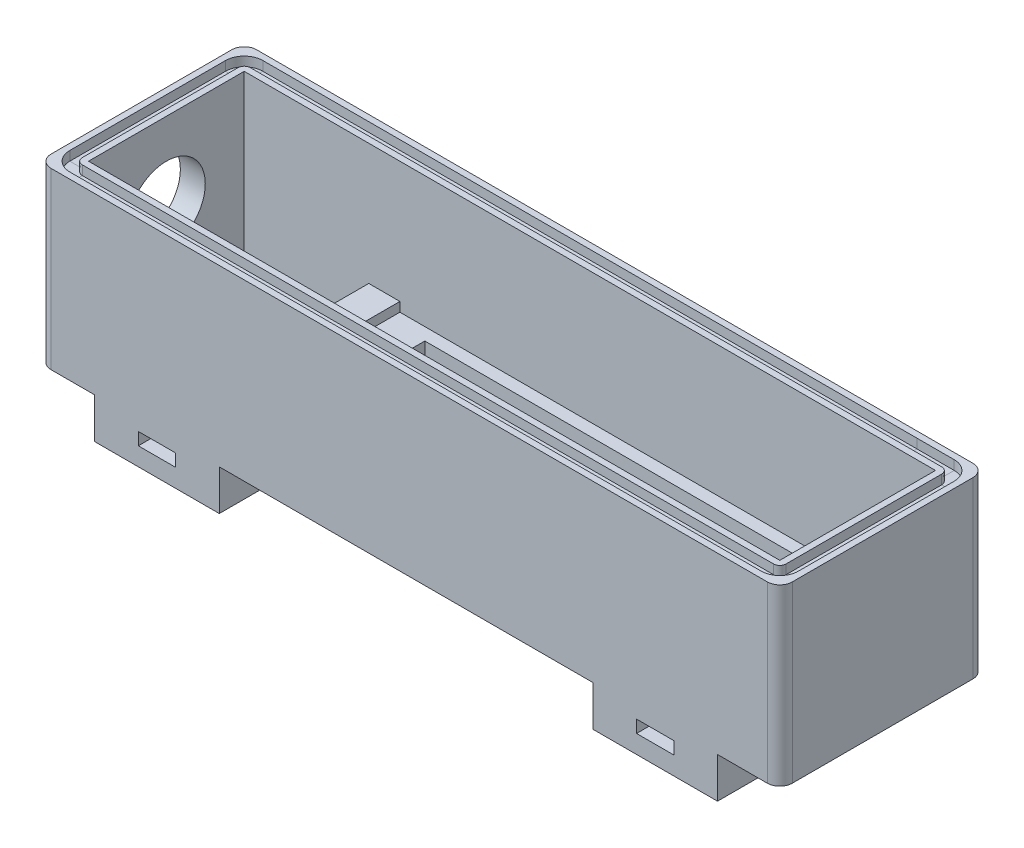
from build123d import *

# Parameters (mm, degrees)
SZKIC5_W                    = 119
SZKIC5_H                    = 33
DODANIE_WYCI_GNI_CIE3_DEPTH = 3
SZKIC6_W                    = 119
SZKIC6_H                    = 33
SZKIC6_W_2                  = 111
SZKIC6_H_2                  = 25
DODANIE_WYCI_GNI_CIE4_DEPTH = 25
SZKIC7_W                    = 91
SZKIC7_H                    = 25
SZKIC7_W_2                  = 69
SZKIC7_H_2                  = 21
DODANIE_WYCI_GNI_CIE5_DEPTH = 4
SZKIC8_W                    = 5
SZKIC8_H                    = 25
SZKIC8_W_2                  = 7
DODANIE_WYCI_GNI_CIE6_DEPTH = 1.5
SZKIC10_R                   = 6.25
WYTNIJ_WYCI_GNI_CIE1_DEPTH  = 7.5
SZKIC22_W                   = 2
SZKIC22_H                   = 3
BOSS_EXTRUDE2_DEPTH         = 20
FILLET1_R                   = 2
SKETCH2_W                   = 6
SKETCH2_H                   = 2
CUT_EXTRUDE1_DEPTH          = 33
FILLET2_R                   = 2
FILLET3_R                   = 2
CUT_EXTRUDE2_DEPTH          = 111


with BuildPart() as part:
    # Szkic5 → Dodanie-wyciągnięcie3 (new body)
    with BuildSketch(Plane(origin=(0, 0, 0), x_dir=(1, 0, 0), z_dir=(0, 1, 0))):
        Rectangle(SZKIC5_W, SZKIC5_H)
    extrude(amount=DODANIE_WYCI_GNI_CIE3_DEPTH)

    # Szkic6 → Dodanie-wyciągnięcie4 (add)
    with BuildSketch(Plane(origin=(0, 3, 0), x_dir=(1, 0, 0), z_dir=(0, 1, 0))):
        Rectangle(SZKIC6_W, SZKIC6_H)
        Rectangle(SZKIC6_W_2, SZKIC6_H_2, mode=Mode.SUBTRACT)
    extrude(amount=DODANIE_WYCI_GNI_CIE4_DEPTH)

    # Szkic7 → Dodanie-wyciągnięcie5 (add)
    with BuildSketch(Plane(origin=(0, 3, 0), x_dir=(1, 0, 0), z_dir=(0, 1, 0))):
        with Locations((10, 0)):
            Rectangle(SZKIC7_W, SZKIC7_H)
        with Locations((10, 0)):
            Rectangle(SZKIC7_W_2, SZKIC7_H_2, mode=Mode.SUBTRACT)
    extrude(amount=DODANIE_WYCI_GNI_CIE5_DEPTH)

    # Szkic8 → Dodanie-wyciągnięcie6 (add)
    with BuildSketch(Plane(origin=(0, 7, 0), x_dir=(1, 0, 0), z_dir=(0, 1, 0))):
        with Locations((-33, 0)):
            Rectangle(SZKIC8_W, SZKIC8_H)
        with Locations((52, 0)):
            Rectangle(SZKIC8_W_2, SZKIC8_H)
    extrude(amount=DODANIE_WYCI_GNI_CIE6_DEPTH)

    # Szkic10 → Wytnij-wyciągnięcie1 (cut)
    with BuildSketch(Plane(origin=(-55.5, 0, 0), x_dir=(0, 0, -1), z_dir=(1, 0, 0))):
        with Locations((0, 15.5)):
            Circle(SZKIC10_R)
    extrude(amount=-WYTNIJ_WYCI_GNI_CIE1_DEPTH, mode=Mode.SUBTRACT)

    # Wycięcie-wyciągnięcie po ścieżce1: sweep along a path in Szkic21
    with BuildLine(Plane(origin=(0, 28, 0), x_dir=(1, 0, 0), z_dir=(0, 1, 0))) as wyci_cie_wyci_gni_cie_po_cie_ce1_path:
        Line((-55.5, 14.5), (55.5, 14.5))
        ThreePointArc((55.5, 14.5), (56.914213562, 13.914213562), (57.5, 12.5))
        Line((57.5, 12.5), (57.5, -12.5))
        ThreePointArc((57.5, -12.5), (56.914213562, -13.914213562), (55.5, -14.5))
        Line((55.5, -14.5), (-55.5, -14.5))
        ThreePointArc((-55.5, -14.5), (-56.914213562, -13.914213562), (-57.5, -12.5))
        Line((-57.5, -12.5), (-57.5, 12.5))
        ThreePointArc((-57.5, 12.5), (-56.914213562, 13.914213562), (-55.5, 14.5))
    # Szkic22 → Wycięcie-wyciągnięcie po ścieżce1 (sweep, cut)
    with BuildSketch(Plane(origin=(49.5, 0, 0), x_dir=(0, 0, -1), z_dir=(1, 0, 0))):
        with Locations((14.5, 28)):
            Rectangle(SZKIC22_W, SZKIC22_H)
    sweep(path=wyci_cie_wyci_gni_cie_po_cie_ce1_path.line, mode=Mode.SUBTRACT)

    # Sketch1 → Boss-Extrude2 (add)
    with BuildSketch(Plane(origin=(49.5, 0, 0), x_dir=(0, 0, -1), z_dir=(1, 0, 0))):
        with BuildLine():
            Line((-16.5, 0), (16.5, 0))
            Line((16.5, 0), (16.5, -9))
            Line((16.5, -9), (17.83044843, -12))
            Line((17.83044843, -12), (18, -18.997946289))
            Line((18, -18.997946289), (12.5, -18.997946289))
            ThreePointArc((12.5, -18.997946289), (0, -6.497946289), (-12.5, -18.997946289))
            Line((-12.5, -18.997946289), (-18, -18.997946289))
            Line((-18, -18.997946289), (-17.83044843, -12))
            Line((-17.83044843, -12), (-16.5, -9))
            Line((-16.5, -9), (-16.5, 0))
        make_face()
    boss_extrude2 = extrude(amount=-BOSS_EXTRUDE2_DEPTH)

    # Fillet1
    fillet1_edges = [part.edges().sort_by_distance(p)[0] for p in [
        (39.5, -12, -17.83044843),
        (39.5, -18.997946289, -18),
        (39.5, -18.997946289, 18),
        (39.5, -12, 17.83044843),
        (39.5, -9, 16.5),
        (39.5, -9, -16.5),
    ]]
    fillet(fillet1_edges, radius=FILLET1_R)

    # Sketch2 → Cut-Extrude1 (cut)
    with BuildSketch(Plane.XY.offset(16.5)):
        with Locations((39.5, -2.576410505)):
            Rectangle(SKETCH2_W, SKETCH2_H)
    cut_extrude1 = extrude(amount=-CUT_EXTRUDE1_DEPTH, mode=Mode.SUBTRACT)

    # Mirror1: Boss-Extrude2 across plane
    add(boss_extrude2.mirror(Plane(origin=(-0.5, 0, 0), x_dir=(0, 0, 1), z_dir=(1, 0, 0))))

    # Mirror4: Cut-Extrude1 across plane
    add(cut_extrude1.mirror(Plane(origin=(-0.5, 0, 0), x_dir=(0, 0, 1), z_dir=(1, 0, 0))), mode=Mode.SUBTRACT)

    # Fillet2
    fillet2_edges = [part.edges().sort_by_distance(p)[0] for p in [
        (-40.5, -18.997946289, -18),
        (-40.5, -12, -17.83044843),
        (-40.5, -9, -16.5),
        (-40.5, -9, 16.5),
        (-40.5, -12, 17.83044843),
        (-40.5, -18.997946289, 18),
    ]]
    fillet(fillet2_edges, radius=FILLET2_R)

    # Fillet3
    fillet3_edges = [part.edges().sort_by_distance(p)[0] for p in [
        (59.5, 14, 16.5),
        (-59.5, 14, 16.5),
        (-59.5, 14, -16.5),
        (59.5, 14, -16.5),
    ]]
    fillet(fillet3_edges, radius=FILLET3_R)

    # Sketch3 → Cut-Extrude2 (cut, through all)
    with BuildSketch(Plane.ZY.offset(50.5)):
        Polygon((0, -6.497946289), (29.072487689, -6.497946289), (29.072487689, -24.547767437), (-22.707347074, -24.547767437), (-22.707347074, -6.497946289), align=None)
    extrude(amount=-CUT_EXTRUDE2_DEPTH, mode=Mode.SUBTRACT)


solid = part.part
